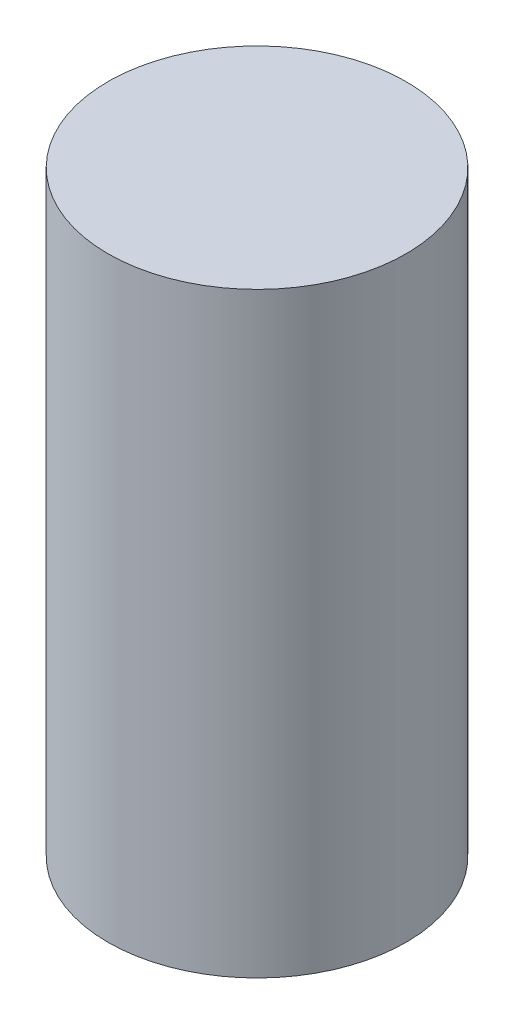
from build123d import *

# Parameters (mm, degrees)
CROQUIS1_R              = 52.5
SALIENTE_EXTRUIR1_DEPTH = 210
CROQUIS2_R              = 42
CORTAR_EXTRUIR1_DEPTH   = 196


with BuildPart() as part:
    # Croquis1 → Saliente-Extruir1 (new body)
    with BuildSketch(Plane(origin=(0, 0, 0), x_dir=(1, 0, 0), z_dir=(0, 1, 0))):
        Circle(CROQUIS1_R)
    extrude(amount=SALIENTE_EXTRUIR1_DEPTH)

    # Croquis2 → Cortar-Extruir1 (cut)
    with BuildSketch(Plane.XZ):
        Circle(CROQUIS2_R)
    extrude(amount=-CORTAR_EXTRUIR1_DEPTH, mode=Mode.SUBTRACT)


solid = part.part
